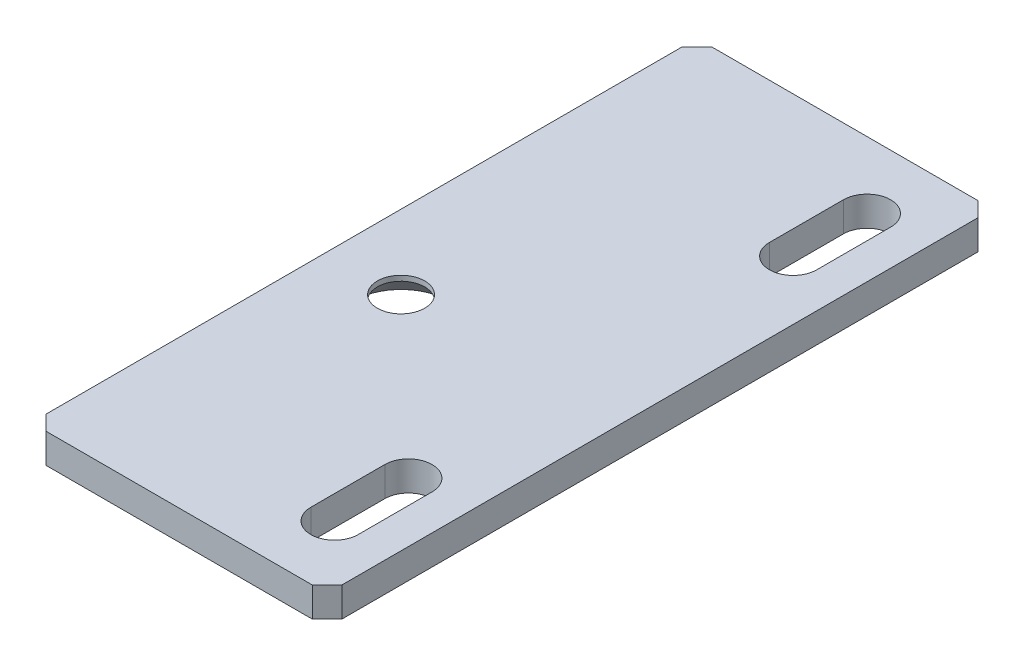
from build123d import *

# Parameters (mm, degrees)
SKETCH1_W        = 20
SKETCH1_H        = 45
BASESHEET_DEPTH  = 2
SCREWSLOTS_DEPTH = 3
CHAMFER1X45_SIZE = 1


with BuildPart() as part:
    # Sketch1 → BaseSheet (new body)
    with BuildSketch(Plane(origin=(0, 0, 0), x_dir=(1, 0, 0), z_dir=(0, 1, 0))):
        Rectangle(SKETCH1_W, SKETCH1_H)
    extrude(amount=BASESHEET_DEPTH)

    # Sketch6 → ScrewSlots (cut, through all)
    with BuildSketch(Plane(origin=(0, 2, 0), x_dir=(1, 0, 0), z_dir=(0, 1, 0))):
        with BuildLine():
            Line((7.6, 18), (7.6, 13))
            ThreePointArc((7.6, 13), (6, 11.4), (4.4, 13))
            Line((4.4, 13), (4.4, 18))
            ThreePointArc((4.4, 18), (6, 19.6), (7.6, 18))
        make_face()
        with BuildLine():
            Line((7.6, -13), (7.6, -18))
            ThreePointArc((7.6, -18), (6, -19.6), (4.4, -18))
            Line((4.4, -18), (4.4, -13))
            ThreePointArc((4.4, -13), (6, -11.4), (7.6, -13))
        make_face()
    extrude(amount=-SCREWSLOTS_DEPTH, mode=Mode.SUBTRACT)

    # Sketch5 → PulleyHole (revolve, cut)
    with BuildSketch(Plane(origin=(-5, 0, 2.5), x_dir=(0, 0, -1), z_dir=(1, 0, 0))):
        Polygon((0, 0), (0, 2), (1.6, 2), (1.6, 1.65), (3.25, 0), align=None)
    revolve(axis=Axis((-5, -6.35, 2.5), (0, 1, 0)), mode=Mode.SUBTRACT)

    # Chamfer1x45
    chamfer1x45_edges = [part.edges().sort_by_distance(p)[0] for p in [
        (-10, 1, -22.5),
        (10, 1, -22.5),
        (10, 1, 22.5),
        (-10, 1, 22.5),
    ]]
    chamfer(chamfer1x45_edges, length=CHAMFER1X45_SIZE)


solid = part.part
